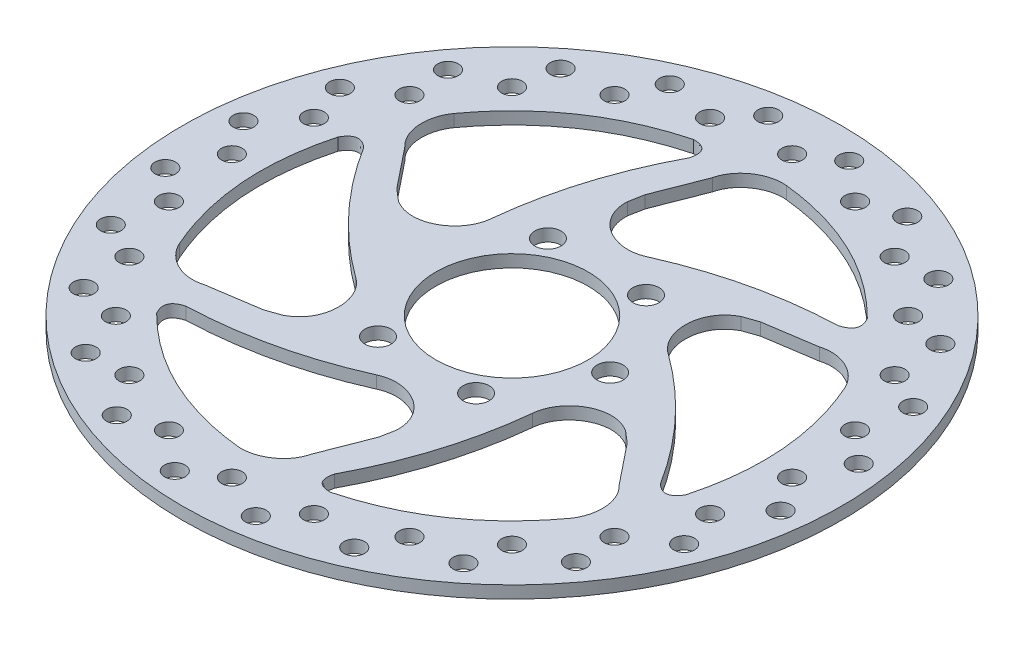
from build123d import *

# Parameters (mm, degrees)
SKETCH1_R           = 80
SKETCH1_R_2         = 2.5
SKETCH1_R_3         = 18.5
SKETCH1_R_4         = 3.175
BOSS_EXTRUDE1_DEPTH = 3


with BuildPart() as part:
    # Sketch1 → Boss-Extrude1 (new body)
    with BuildSketch(Plane(origin=(0, 0, 0), x_dir=(1, 0, 0), z_dir=(0, 1, 0))):
        Circle(SKETCH1_R)
        with Locations((0, 68)):
            Circle(SKETCH1_R_2, mode=Mode.SUBTRACT)
        with Locations((8.332202922, 73.529411765)):
            Circle(SKETCH1_R_2, mode=Mode.SUBTRACT)
        with Locations((17.599695067, 65.682956188)):
            Circle(SKETCH1_R_2, mode=Mode.SUBTRACT)
        with Locations((27.079102132, 68.867425011)):
            Circle(SKETCH1_R_2, mode=Mode.SUBTRACT)
        with Locations((34, 58.889727457)):
            Circle(SKETCH1_R_2, mode=Mode.SUBTRACT)
        with Locations((43.980605282, 59.512237052)):
            Circle(SKETCH1_R_2, mode=Mode.SUBTRACT)
        with Locations((48.083261121, 48.083261121)):
            Circle(SKETCH1_R_2, mode=Mode.SUBTRACT)
        with Locations((57.884902864, 46.101388487)):
            Circle(SKETCH1_R_2, mode=Mode.SUBTRACT)
        with Locations((58.889727457, 34)):
            Circle(SKETCH1_R_2, mode=Mode.SUBTRACT)
        with Locations((67.844439975, 29.548806482)):
            Circle(SKETCH1_R_2, mode=Mode.SUBTRACT)
        with Locations((65.682956188, 17.599695067)):
            Circle(SKETCH1_R_2, mode=Mode.SUBTRACT)
        with Locations((73.180490619, 10.982522147)):
            Circle(SKETCH1_R_2, mode=Mode.SUBTRACT)
        with Locations((68, 0)):
            Circle(SKETCH1_R_2, mode=Mode.SUBTRACT)
        with Locations((73.529411765, -8.332202922)):
            Circle(SKETCH1_R_2, mode=Mode.SUBTRACT)
        with Locations((65.682956188, -17.599695067)):
            Circle(SKETCH1_R_2, mode=Mode.SUBTRACT)
        with Locations((68.867425011, -27.079102132)):
            Circle(SKETCH1_R_2, mode=Mode.SUBTRACT)
        with Locations((58.889727457, -34)):
            Circle(SKETCH1_R_2, mode=Mode.SUBTRACT)
        with Locations((59.512237052, -43.980605282)):
            Circle(SKETCH1_R_2, mode=Mode.SUBTRACT)
        with Locations((48.083261121, -48.083261121)):
            Circle(SKETCH1_R_2, mode=Mode.SUBTRACT)
        with Locations((46.101388487, -57.884902864)):
            Circle(SKETCH1_R_2, mode=Mode.SUBTRACT)
        with Locations((34, -58.889727457)):
            Circle(SKETCH1_R_2, mode=Mode.SUBTRACT)
        with Locations((29.548806482, -67.844439975)):
            Circle(SKETCH1_R_2, mode=Mode.SUBTRACT)
        with Locations((17.599695067, -65.682956188)):
            Circle(SKETCH1_R_2, mode=Mode.SUBTRACT)
        with Locations((10.982522147, -73.180490619)):
            Circle(SKETCH1_R_2, mode=Mode.SUBTRACT)
        with Locations((0, -68)):
            Circle(SKETCH1_R_2, mode=Mode.SUBTRACT)
        with Locations((-8.332202922, -73.529411765)):
            Circle(SKETCH1_R_2, mode=Mode.SUBTRACT)
        with Locations((-17.599695067, -65.682956188)):
            Circle(SKETCH1_R_2, mode=Mode.SUBTRACT)
        with Locations((-27.079102132, -68.867425011)):
            Circle(SKETCH1_R_2, mode=Mode.SUBTRACT)
        with Locations((-34, -58.889727457)):
            Circle(SKETCH1_R_2, mode=Mode.SUBTRACT)
        with Locations((-43.980605282, -59.512237052)):
            Circle(SKETCH1_R_2, mode=Mode.SUBTRACT)
        with Locations((-48.083261121, -48.083261121)):
            Circle(SKETCH1_R_2, mode=Mode.SUBTRACT)
        with Locations((-57.884902864, -46.101388487)):
            Circle(SKETCH1_R_2, mode=Mode.SUBTRACT)
        with Locations((-58.889727457, -34)):
            Circle(SKETCH1_R_2, mode=Mode.SUBTRACT)
        with Locations((-67.844439975, -29.548806482)):
            Circle(SKETCH1_R_2, mode=Mode.SUBTRACT)
        with Locations((-65.682956188, -17.599695067)):
            Circle(SKETCH1_R_2, mode=Mode.SUBTRACT)
        with Locations((-73.180490619, -10.982522147)):
            Circle(SKETCH1_R_2, mode=Mode.SUBTRACT)
        with Locations((-68, 0)):
            Circle(SKETCH1_R_2, mode=Mode.SUBTRACT)
        with Locations((-73.529411765, 8.332202922)):
            Circle(SKETCH1_R_2, mode=Mode.SUBTRACT)
        with Locations((-65.682956188, 17.599695067)):
            Circle(SKETCH1_R_2, mode=Mode.SUBTRACT)
        with Locations((-68.867425011, 27.079102132)):
            Circle(SKETCH1_R_2, mode=Mode.SUBTRACT)
        with Locations((-58.889727457, 34)):
            Circle(SKETCH1_R_2, mode=Mode.SUBTRACT)
        with Locations((-59.512237052, 43.980605282)):
            Circle(SKETCH1_R_2, mode=Mode.SUBTRACT)
        with Locations((-48.083261121, 48.083261121)):
            Circle(SKETCH1_R_2, mode=Mode.SUBTRACT)
        with Locations((-46.101388487, 57.884902864)):
            Circle(SKETCH1_R_2, mode=Mode.SUBTRACT)
        with Locations((-34, 58.889727457)):
            Circle(SKETCH1_R_2, mode=Mode.SUBTRACT)
        with Locations((-29.548806482, 67.844439975)):
            Circle(SKETCH1_R_2, mode=Mode.SUBTRACT)
        with Locations((-17.599695067, 65.682956188)):
            Circle(SKETCH1_R_2, mode=Mode.SUBTRACT)
        with Locations((-10.982522147, 73.180490619)):
            Circle(SKETCH1_R_2, mode=Mode.SUBTRACT)
        Circle(SKETCH1_R_3, mode=Mode.SUBTRACT)
        with Locations((-11.90625, 20.622229928)):
            Circle(SKETCH1_R_4, mode=Mode.SUBTRACT)
        with Locations((11.90625, 20.622229928)):
            Circle(SKETCH1_R_4, mode=Mode.SUBTRACT)
        with Locations((23.8125, 0)):
            Circle(SKETCH1_R_4, mode=Mode.SUBTRACT)
        with Locations((11.90625, -20.622229928)):
            Circle(SKETCH1_R_4, mode=Mode.SUBTRACT)
        with Locations((-11.90625, -20.622229928)):
            Circle(SKETCH1_R_4, mode=Mode.SUBTRACT)
        with BuildLine():
            Line((-9.315993321, 41.634868421), (-4.742741297, 53.355893883))
            add(Edge.make_bspline(
                [(-4.742741297, 53.355893883), (-3.617179994, 58.141088286), (1.364432068, 61.178922208), (5.953223317, 60.708806051)],
                knots=[0, 0, 0, 0, 1, 1, 1, 1], degree=3))
            add(Edge.make_bspline(
                [(5.953223317, 60.708806051), (27.994120627, 58.322754235), (43.642459298, 42.618490663)],
                knots=[0, 0, 0, 1, 1, 1], degree=2))
            add(Edge.make_bspline(
                [(41.595098769, 37.524132931), (45.940667236, 38.736285254), (43.642459298, 42.618490663)],
                knots=[0, 0, 0, 1, 1, 1], degree=2))
            add(Edge.make_bspline(
                [(4.081342093, 28.870780607), (21.997498313, 36.842130391), (41.595098769, 37.524132931)],
                knots=[0, 0, 0, 1, 1, 1], degree=2))
            add(Edge.make_bspline(
                [(4.081342093, 28.870780607), (-1.887276933, 26.023157642), (-10.304245695, 30.434997813), (-10, 38)],
                knots=[0, 0, 0, 0, 1, 1, 1, 1], degree=3))
            add(Edge.make_bspline(
                [(-10, 38), (-9.315993321, 41.634868421)],
                knots=[0, 0, 1, 1], degree=1))
        make_face(mode=Mode.SUBTRACT)
        with BuildLine():
            Line((31.398857075, 28.885321088), (43.836188896, 30.785281388))
            add(Edge.make_bspline(
                [(43.836188896, 30.785281388), (48.543069462, 32.203113908), (53.664716842, 29.407828271), (55.551979932, 25.198760399)],
                knots=[0, 0, 0, 0, 1, 1, 1, 1], degree=3))
            add(Edge.make_bspline(
                [(55.551979932, 25.198760399), (64.5060471, 4.917757498), (58.729925234, -16.486233105)],
                knots=[0, 0, 0, 1, 1, 1], degree=2))
            add(Edge.make_bspline(
                [(53.294401758, -17.260345741), (56.516940696, -20.417642266), (58.729925234, -16.486233105)],
                knots=[0, 0, 0, 1, 1, 1], degree=2))
            add(Edge.make_bspline(
                [(27.043500479, 10.90084437), (42.904970004, -0.629327163), (53.294401758, -17.260345741)],
                knots=[0, 0, 0, 1, 1, 1], degree=2))
            add(Edge.make_bspline(
                [(27.043500479, 10.90084437), (21.593077138, 14.646008589), (21.205358423, 24.141237446), (27.908965344, 27.660254038)],
                knots=[0, 0, 0, 0, 1, 1, 1, 1], degree=3))
            add(Edge.make_bspline(
                [(27.908965344, 27.660254038), (31.398857075, 28.885321088)],
                knots=[0, 0, 1, 1], degree=1))
        make_face(mode=Mode.SUBTRACT)
        with BuildLine():
            Line((40.714850396, -12.749547333), (48.578930193, -22.570612494))
            add(Edge.make_bspline(
                [(48.578930193, -22.570612494), (52.160249457, -25.937974378), (52.300284774, -31.771093936), (49.598756615, -35.510045652)],
                knots=[0, 0, 0, 0, 1, 1, 1, 1], degree=3))
            add(Edge.make_bspline(
                [(49.598756615, -35.510045652), (36.511926472, -53.404996737), (15.087465936, -59.104723768)],
                knots=[0, 0, 0, 1, 1, 1], degree=2))
            add(Edge.make_bspline(
                [(11.699302989, -54.784478672), (10.576273461, -59.15392752), (15.087465936, -59.104723768)],
                knots=[0, 0, 0, 1, 1, 1], degree=2))
            add(Edge.make_bspline(
                [(22.962158387, -17.969936237), (20.907471691, -37.471457554), (11.699302989, -54.784478672)],
                knots=[0, 0, 0, 1, 1, 1], degree=2))
            add(Edge.make_bspline(
                [(22.962158387, -17.969936237), (23.480354071, -11.377149053), (31.509604118, -6.293760367), (37.908965344, -10.339745962)],
                knots=[0, 0, 0, 0, 1, 1, 1, 1], degree=3))
            add(Edge.make_bspline(
                [(37.908965344, -10.339745962), (40.714850396, -12.749547333)],
                knots=[0, 0, 1, 1], degree=1))
        make_face(mode=Mode.SUBTRACT)
        with BuildLine():
            Line((9.315993321, -41.634868421), (4.742741297, -53.355893883))
            add(Edge.make_bspline(
                [(4.742741297, -53.355893883), (3.617179994, -58.141088286), (-1.364432068, -61.178922208), (-5.953223317, -60.708806051)],
                knots=[0, 0, 0, 0, 1, 1, 1, 1], degree=3))
            add(Edge.make_bspline(
                [(-5.953223317, -60.708806051), (-27.994120627, -58.322754235), (-43.642459298, -42.618490663)],
                knots=[0, 0, 0, 1, 1, 1], degree=2))
            add(Edge.make_bspline(
                [(-41.595098769, -37.524132931), (-45.940667236, -38.736285254), (-43.642459298, -42.618490663)],
                knots=[0, 0, 0, 1, 1, 1], degree=2))
            add(Edge.make_bspline(
                [(-4.081342093, -28.870780607), (-21.997498313, -36.842130391), (-41.595098769, -37.524132931)],
                knots=[0, 0, 0, 1, 1, 1], degree=2))
            add(Edge.make_bspline(
                [(-4.081342093, -28.870780607), (1.887276933, -26.023157642), (10.304245695, -30.434997813), (10, -38)],
                knots=[0, 0, 0, 0, 1, 1, 1, 1], degree=3))
            add(Edge.make_bspline(
                [(10, -38), (9.315993321, -41.634868421)],
                knots=[0, 0, 1, 1], degree=1))
        make_face(mode=Mode.SUBTRACT)
        with BuildLine():
            Line((-31.398857075, -28.885321088), (-43.836188896, -30.785281388))
            add(Edge.make_bspline(
                [(-43.836188896, -30.785281388), (-48.543069462, -32.203113908), (-53.664716842, -29.407828271), (-55.551979932, -25.198760399)],
                knots=[0, 0, 0, 0, 1, 1, 1, 1], degree=3))
            add(Edge.make_bspline(
                [(-55.551979932, -25.198760399), (-64.5060471, -4.917757498), (-58.729925234, 16.486233105)],
                knots=[0, 0, 0, 1, 1, 1], degree=2))
            add(Edge.make_bspline(
                [(-53.294401758, 17.260345741), (-56.516940696, 20.417642266), (-58.729925234, 16.486233105)],
                knots=[0, 0, 0, 1, 1, 1], degree=2))
            add(Edge.make_bspline(
                [(-27.043500479, -10.90084437), (-42.904970004, 0.629327163), (-53.294401758, 17.260345741)],
                knots=[0, 0, 0, 1, 1, 1], degree=2))
            add(Edge.make_bspline(
                [(-27.043500479, -10.90084437), (-21.593077138, -14.646008589), (-21.205358423, -24.141237446), (-27.908965344, -27.660254038)],
                knots=[0, 0, 0, 0, 1, 1, 1, 1], degree=3))
            add(Edge.make_bspline(
                [(-27.908965344, -27.660254038), (-31.398857075, -28.885321088)],
                knots=[0, 0, 1, 1], degree=1))
        make_face(mode=Mode.SUBTRACT)
        with BuildLine():
            Line((-40.714850396, 12.749547333), (-48.578930193, 22.570612494))
            add(Edge.make_bspline(
                [(-48.578930193, 22.570612494), (-52.160249457, 25.937974378), (-52.300284774, 31.771093936), (-49.598756615, 35.510045652)],
                knots=[0, 0, 0, 0, 1, 1, 1, 1], degree=3))
            add(Edge.make_bspline(
                [(-49.598756615, 35.510045652), (-36.511926472, 53.404996737), (-15.087465936, 59.104723768)],
                knots=[0, 0, 0, 1, 1, 1], degree=2))
            add(Edge.make_bspline(
                [(-11.699302989, 54.784478672), (-10.576273461, 59.15392752), (-15.087465936, 59.104723768)],
                knots=[0, 0, 0, 1, 1, 1], degree=2))
            add(Edge.make_bspline(
                [(-22.962158387, 17.969936237), (-20.907471691, 37.471457554), (-11.699302989, 54.784478672)],
                knots=[0, 0, 0, 1, 1, 1], degree=2))
            add(Edge.make_bspline(
                [(-22.962158387, 17.969936237), (-23.480354071, 11.377149053), (-31.509604118, 6.293760367), (-37.908965344, 10.339745962)],
                knots=[0, 0, 0, 0, 1, 1, 1, 1], degree=3))
            add(Edge.make_bspline(
                [(-37.908965344, 10.339745962), (-40.714850396, 12.749547333)],
                knots=[0, 0, 1, 1], degree=1))
        make_face(mode=Mode.SUBTRACT)
    extrude(amount=BOSS_EXTRUDE1_DEPTH)


solid = part.part
